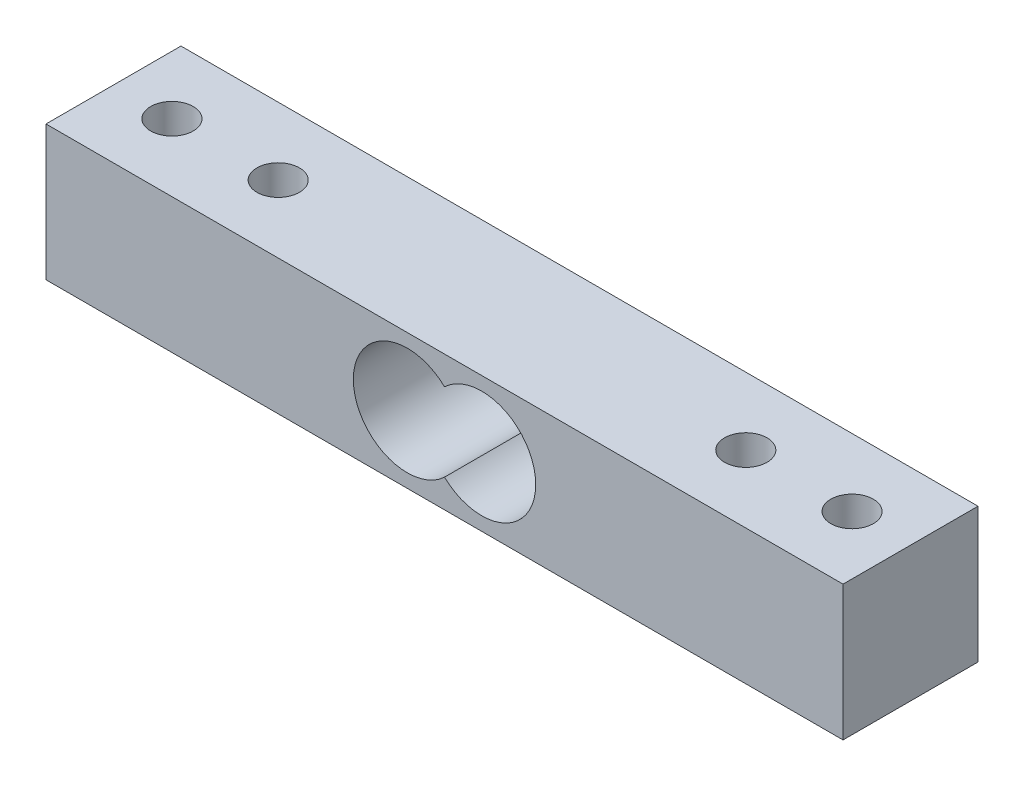
from build123d import *

# Parameters (mm, degrees)
SKETCH1_W               = 75
SKETCH1_H               = 12.7
LOADCELL_DEPTH          = 6.35
SKETCH2_R               = 2
CUT_EXTRUDE1_DEPTH      = 7.35
CUT_EXTRUDE1_DEPTH_BACK = 7.35


with BuildPart() as part:
    # Sketch1 → LoadCell (new body, symmetric)
    with BuildSketch(Plane.XY):
        Rectangle(SKETCH1_W, SKETCH1_H)
        with BuildLine():
            ThreePointArc((0, 3.681901683), (-8.58, 0), (0, -3.681901683))
            ThreePointArc((0, -3.681901683), (8.58, 0), (0, 3.681901683))
        make_face(mode=Mode.SUBTRACT)
    extrude(amount=LOADCELL_DEPTH, both=True)

    # Sketch2 → Cut-Extrude1 (cut, two sides)
    with BuildSketch(Plane(origin=(0, 0, 0), x_dir=(1, 0, 0), z_dir=(0, 1, 0))) as cut_extrude1_sk:
        with Locations((-31.999999942, 0)):
            Circle(SKETCH2_R)
        with Locations((-21.999999942, 0)):
            Circle(SKETCH2_R)
        with Locations((31.999999942, 0)):
            Circle(SKETCH2_R)
        with Locations((21.999999942, 0)):
            Circle(SKETCH2_R)
    extrude(amount=CUT_EXTRUDE1_DEPTH, mode=Mode.SUBTRACT)
    extrude(cut_extrude1_sk.sketch, amount=-CUT_EXTRUDE1_DEPTH_BACK, mode=Mode.SUBTRACT)


solid = part.part
